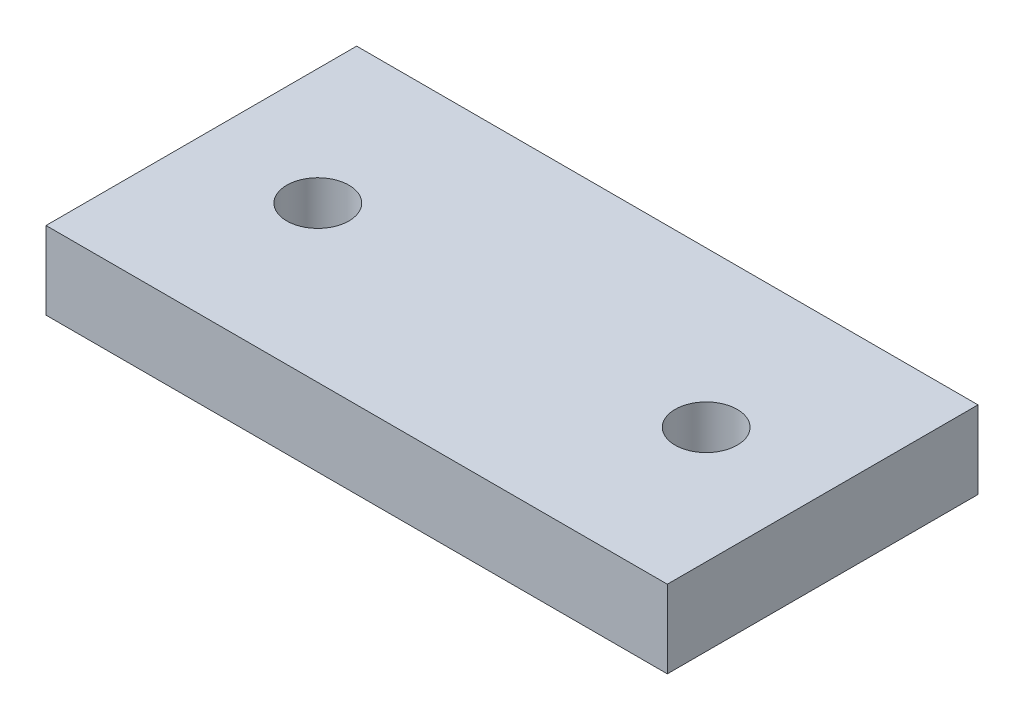
from build123d import *

# Parameters (mm, degrees)
SKETCH1_W           = 40
SKETCH1_H           = 20
BOSS_EXTRUDE1_DEPTH = 5
SKETCH2_R           = 2
CUT_EXTRUDE1_DEPTH  = 5


with BuildPart() as part:
    # Sketch1 → Boss-Extrude1 (new body)
    with BuildSketch(Plane(origin=(0, 0, 0), x_dir=(1, 0, 0), z_dir=(0, 1, 0))):
        Rectangle(SKETCH1_W, SKETCH1_H)
    extrude(amount=BOSS_EXTRUDE1_DEPTH)

    # Sketch2 → Cut-Extrude1 (cut)
    with BuildSketch(Plane(origin=(0, 5, 0), x_dir=(1, 0, 0), z_dir=(0, 1, 0))):
        with Locations((-12.5, 0)):
            Circle(SKETCH2_R)
        with Locations((12.5, 0)):
            Circle(SKETCH2_R)
    extrude(amount=-CUT_EXTRUDE1_DEPTH, mode=Mode.SUBTRACT)


solid = part.part
